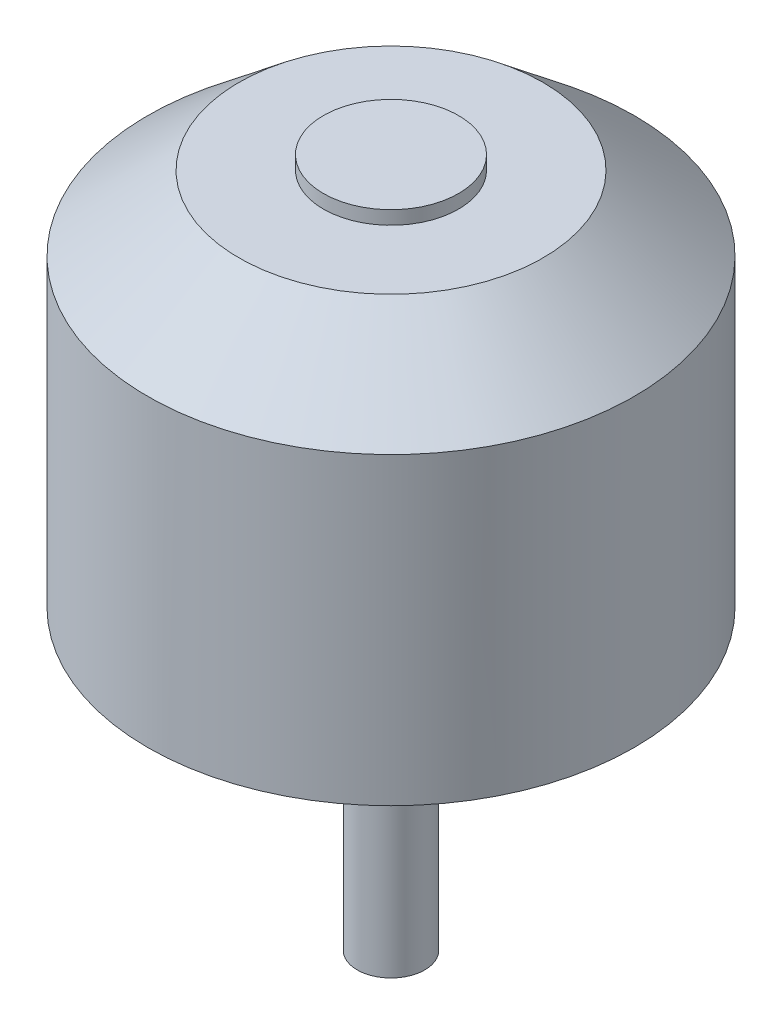
from build123d import *

# Parameters (mm, degrees)
CROQUIS1_R              = 18
SALIENTE_EXTRUIR1_DEPTH = 29
CROQUIS2_R              = 2.5
SALIENTE_EXTRUIR2_DEPTH = 22
CROQUIS3_R              = 18
CROQUIS3_R_2            = 5
CORTAR_EXTRUIR1_DEPTH   = 1


with BuildPart() as part:
    # Croquis1 → Saliente-Extruir1 (new body)
    with BuildSketch(Plane(origin=(0, 0, 0), x_dir=(1, 0, 0), z_dir=(0, 1, 0))):
        Circle(CROQUIS1_R)
    extrude(amount=SALIENTE_EXTRUIR1_DEPTH)

    # Croquis2 → Saliente-Extruir2 (add)
    with BuildSketch(Plane.XZ):
        Circle(CROQUIS2_R)
    extrude(amount=SALIENTE_EXTRUIR2_DEPTH)

    # Croquis3 → Cortar-Extruir1 (cut)
    with BuildSketch(Plane(origin=(0, 29, 0), x_dir=(1, 0, 0), z_dir=(0, 1, 0))):
        Circle(CROQUIS3_R)
        Circle(CROQUIS3_R_2, mode=Mode.SUBTRACT)
    extrude(amount=-CORTAR_EXTRUIR1_DEPTH, mode=Mode.SUBTRACT)

    # Croquis4 → Cortar-Revolución1 (revolve, cut)
    with BuildSketch(Plane.XY):
        Polygon((-18, 22.5), (-11.25, 28), (-18, 28), align=None)
    revolve(axis=Axis((0, 0, 0), (0, 1, 0)), mode=Mode.SUBTRACT)


solid = part.part
